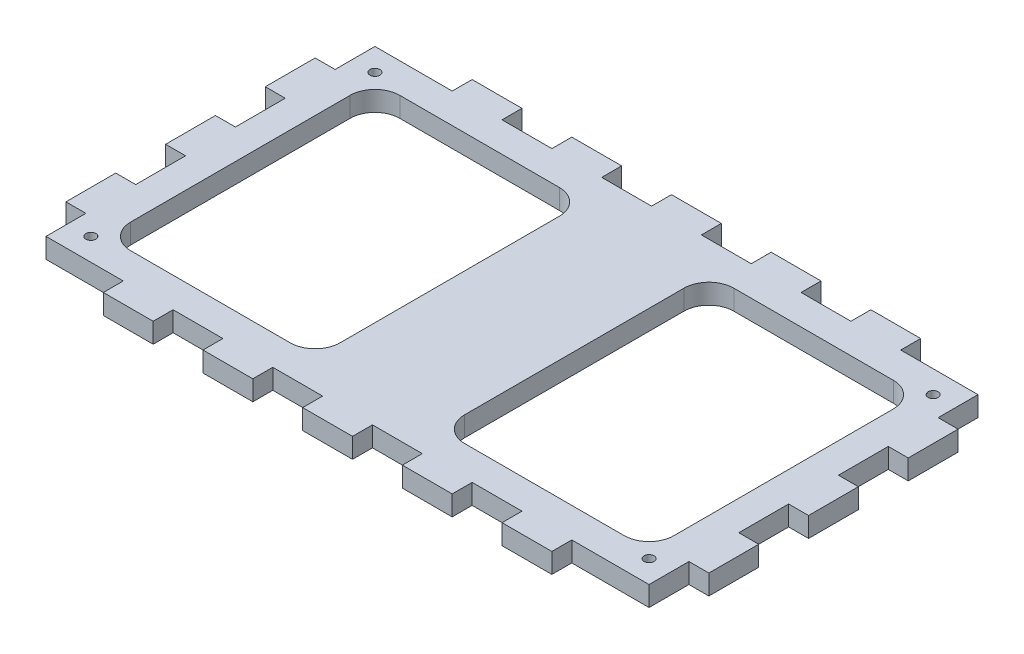
from build123d import *

# Parameters (mm, degrees)
SKETCH1_W           = 121
SKETCH1_H           = 66
BOSS_EXTRUDE1_DEPTH = 4
SKETCH2_W           = 109
SKETCH2_H           = 54
CUT_EXTRUDE1_DEPTH  = 5
FILLET1_R           = 5
SKETCH3_W           = 25
SKETCH3_H           = 54
BOSS_EXTRUDE2_DEPTH = 4
FILLET2_R           = 5
SKETCH4_R           = 1
CUT_EXTRUDE2_DEPTH  = 5
SKETCH5_W           = 10
SKETCH5_H           = 4
BOSS_EXTRUDE3_DEPTH = 4
LPATTERN1_COUNT     = 3
LPATTERN1_PITCH     = 20
LPATTERN1_COL_COUNT = 3
LPATTERN1_COL_PITCH = 20
SKETCH6_W           = 4
SKETCH6_H           = 10
BOSS_EXTRUDE4_DEPTH = 4
LPATTERN2_COUNT     = 2
LPATTERN2_PITCH     = 20
LPATTERN2_COL_COUNT = 2
LPATTERN2_COL_PITCH = 20


with BuildPart() as part:
    # Sketch1 → Boss-Extrude1 (new body)
    with BuildSketch(Plane(origin=(0, 0, 0), x_dir=(1, 0, 0), z_dir=(0, 1, 0))):
        with Locations((60.5, -33)):
            Rectangle(SKETCH1_W, SKETCH1_H)
    extrude(amount=BOSS_EXTRUDE1_DEPTH)

    # Sketch2 → Cut-Extrude1 (cut, through all)
    with BuildSketch(Plane(origin=(0, 4, 0), x_dir=(1, 0, 0), z_dir=(0, 1, 0))):
        with Locations((60.5, -33)):
            Rectangle(SKETCH2_W, SKETCH2_H)
    extrude(amount=-CUT_EXTRUDE1_DEPTH, mode=Mode.SUBTRACT)

    # Fillet1
    fillet1_edges = [part.edges().sort_by_distance(p)[0] for p in [
        (115, 2, 6),
        (115, 2, 60),
        (6, 2, 60),
        (6, 2, 6),
    ]]
    fillet(fillet1_edges, radius=FILLET1_R)

    # Sketch3 → Boss-Extrude2 (add, through all)
    with BuildSketch(Plane(origin=(0, 4, 0), x_dir=(1, 0, 0), z_dir=(0, 1, 0))):
        with Locations((60.5, -33)):
            Rectangle(SKETCH3_W, SKETCH3_H)
    extrude(amount=-BOSS_EXTRUDE2_DEPTH)

    # Fillet2
    fillet2_edges = [part.edges().sort_by_distance(p)[0] for p in [
        (73, 2, 6),
        (73, 2, 60),
        (48, 2, 60),
        (48, 2, 6),
    ]]
    fillet(fillet2_edges, radius=FILLET2_R)

    # Sketch4 → Cut-Extrude2 (cut, through all)
    with BuildSketch(Plane(origin=(0, 4, 0), x_dir=(1, 0, 0), z_dir=(0, 1, 0))):
        with Locations((116.5, -61.5)):
            Circle(SKETCH4_R)
        with Locations((116.5, -4.5)):
            Circle(SKETCH4_R)
        with Locations((4.5, -4.5)):
            Circle(SKETCH4_R)
        with Locations((4.5, -61.5)):
            Circle(SKETCH4_R)
    extrude(amount=-CUT_EXTRUDE2_DEPTH, mode=Mode.SUBTRACT)

    # Sketch5 → Boss-Extrude3 (add, through all)
    with BuildSketch(Plane(origin=(0, 4, 0), x_dir=(1, 0, 0), z_dir=(0, 1, 0))):
        with Locations((60.5, 2)):
            Rectangle(SKETCH5_W, SKETCH5_H)
        with Locations((60.5, -68)):
            Rectangle(SKETCH5_W, SKETCH5_H)
    boss_extrude3 = extrude(amount=-BOSS_EXTRUDE3_DEPTH)

    # LPattern1: Boss-Extrude3 ×3
    with Locations(*[(i * LPATTERN1_PITCH, 0, 0) for i in range(1, LPATTERN1_COUNT)]):
        add(boss_extrude3)

    # LPattern1 col: Boss-Extrude3 ×3
    with Locations(*[(-i * LPATTERN1_COL_PITCH, 0, 0) for i in range(1, LPATTERN1_COL_COUNT)]):
        add(boss_extrude3)

    # Sketch6 → Boss-Extrude4 (add, through all)
    with BuildSketch(Plane(origin=(0, 4, 0), x_dir=(1, 0, 0), z_dir=(0, 1, 0))):
        with Locations((-2, -33)):
            Rectangle(SKETCH6_W, SKETCH6_H)
        with Locations((123, -33)):
            Rectangle(SKETCH6_W, SKETCH6_H)
    boss_extrude4 = extrude(amount=-BOSS_EXTRUDE4_DEPTH)

    # LPattern2: Boss-Extrude4 ×2
    with Locations(*[(0, 0, -i * LPATTERN2_PITCH) for i in range(1, LPATTERN2_COUNT)]):
        add(boss_extrude4)

    # LPattern2 col: Boss-Extrude4 ×2
    with Locations(*[(0, 0, i * LPATTERN2_COL_PITCH) for i in range(1, LPATTERN2_COL_COUNT)]):
        add(boss_extrude4)


solid = part.part
